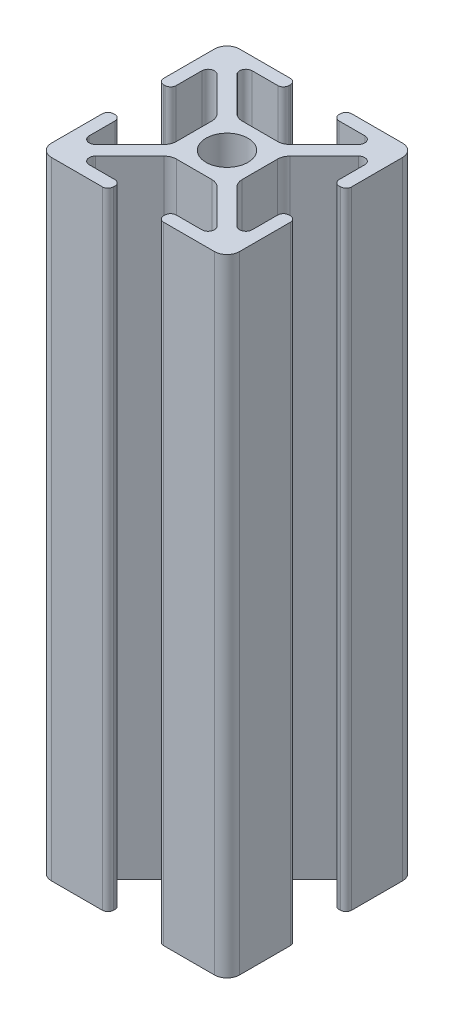
from build123d import *

# Parameters (mm, degrees)
SKETCH1_R       = 3.35
EXTRUSION_DEPTH = 100


with BuildPart() as part:
    # Sketch1 → Extrusion (new body)
    with BuildSketch(Plane(origin=(0, 0, 0), x_dir=(1, 0, 0), z_dir=(0, 1, 0))):
        with BuildLine():
            Line((14.1, -4), (13.9, -4))
            ThreePointArc((13.9, -4), (13.263603897, -4.263603897), (13, -4.9))
            Line((13, -4.9), (13, -8.985786438))
            ThreePointArc((13, -8.985786438), (12.382683432, -9.90966597), (11.292893219, -9.692893219))
            Line((11.292893219, -9.692893219), (5.835786438, -4.235786438))
            ThreePointArc((5.835786438, -4.235786438), (5.402240935, -3.58693974), (5.25, -2.821572875))
            Line((5.25, -2.821572875), (5.25, 2.821572875))
            ThreePointArc((5.25, 2.821572875), (5.402240935, 3.58693974), (5.835786438, 4.235786438))
            Line((5.835786438, 4.235786438), (11.292893219, 9.692893219))
            ThreePointArc((11.292893219, 9.692893219), (12.382683432, 9.90966597), (13, 8.985786438))
            Line((13, 8.985786438), (13, 4.9))
            ThreePointArc((13, 4.9), (13.263603897, 4.263603897), (13.9, 4))
            Line((13.9, 4), (14.1, 4))
            ThreePointArc((14.1, 4), (14.736396103, 4.263603897), (15, 4.9))
            Line((15, 4.9), (15, 13))
            ThreePointArc((15, 13), (14.414213562, 14.414213562), (13, 15))
            Line((13, 15), (4.9, 15))
            ThreePointArc((4.9, 15), (4.263603897, 14.736396103), (4, 14.1))
            Line((4, 14.1), (4, 13.9))
            ThreePointArc((4, 13.9), (4.263603897, 13.263603897), (4.9, 13))
            Line((4.9, 13), (8.985786438, 13))
            ThreePointArc((8.985786438, 13), (9.90966597, 12.382683432), (9.692893219, 11.292893219))
            Line((9.692893219, 11.292893219), (4.235786438, 5.835786438))
            ThreePointArc((4.235786438, 5.835786438), (3.58693974, 5.402240935), (2.821572875, 5.25))
            Line((2.821572875, 5.25), (-2.821572875, 5.25))
            ThreePointArc((-2.821572875, 5.25), (-3.58693974, 5.402240935), (-4.235786438, 5.835786438))
            Line((-4.235786438, 5.835786438), (-9.692893219, 11.292893219))
            ThreePointArc((-9.692893219, 11.292893219), (-9.90966597, 12.382683432), (-8.985786438, 13))
            Line((-8.985786438, 13), (-4.9, 13))
            ThreePointArc((-4.9, 13), (-4.263603897, 13.263603897), (-4, 13.9))
            Line((-4, 13.9), (-4, 14.1))
            ThreePointArc((-4, 14.1), (-4.263603897, 14.736396103), (-4.9, 15))
            Line((-4.9, 15), (-13, 15))
            ThreePointArc((-13, 15), (-14.414213562, 14.414213562), (-15, 13))
            Line((-15, 13), (-15, 4.9))
            ThreePointArc((-15, 4.9), (-14.736396103, 4.263603897), (-14.1, 4))
            Line((-14.1, 4), (-13.9, 4))
            ThreePointArc((-13.9, 4), (-13.263603897, 4.263603897), (-13, 4.9))
            Line((-13, 4.9), (-13, 8.985786438))
            ThreePointArc((-13, 8.985786438), (-12.382683432, 9.90966597), (-11.292893219, 9.692893219))
            Line((-11.292893219, 9.692893219), (-5.835786438, 4.235786438))
            ThreePointArc((-5.835786438, 4.235786438), (-5.402240935, 3.58693974), (-5.25, 2.821572875))
            Line((-5.25, 2.821572875), (-5.25, -2.821572875))
            ThreePointArc((-5.25, -2.821572875), (-5.402240935, -3.58693974), (-5.835786438, -4.235786438))
            Line((-5.835786438, -4.235786438), (-11.292893219, -9.692893219))
            ThreePointArc((-11.292893219, -9.692893219), (-12.382683432, -9.90966597), (-13, -8.985786438))
            Line((-13, -8.985786438), (-13, -4.9))
            ThreePointArc((-13, -4.9), (-13.263603897, -4.263603897), (-13.9, -4))
            Line((-13.9, -4), (-14.1, -4))
            ThreePointArc((-14.1, -4), (-14.736396103, -4.263603897), (-15, -4.9))
            Line((-15, -4.9), (-15, -13))
            ThreePointArc((-15, -13), (-14.414213562, -14.414213562), (-13, -15))
            Line((-13, -15), (-4.9, -15))
            ThreePointArc((-4.9, -15), (-4.263603897, -14.736396103), (-4, -14.1))
            Line((-4, -14.1), (-4, -13.9))
            ThreePointArc((-4, -13.9), (-4.263603897, -13.263603897), (-4.9, -13))
            Line((-4.9, -13), (-8.985786438, -13))
            ThreePointArc((-8.985786438, -13), (-9.90966597, -12.382683432), (-9.692893219, -11.292893219))
            Line((-9.692893219, -11.292893219), (-4.235786438, -5.835786438))
            ThreePointArc((-4.235786438, -5.835786438), (-3.58693974, -5.402240935), (-2.821572875, -5.25))
            Line((-2.821572875, -5.25), (2.821572875, -5.25))
            ThreePointArc((2.821572875, -5.25), (3.58693974, -5.402240935), (4.235786438, -5.835786438))
            Line((4.235786438, -5.835786438), (9.692893219, -11.292893219))
            ThreePointArc((9.692893219, -11.292893219), (9.90966597, -12.382683432), (8.985786438, -13))
            Line((8.985786438, -13), (4.9, -13))
            ThreePointArc((4.9, -13), (4.263603897, -13.263603897), (4, -13.9))
            Line((4, -13.9), (4, -14.1))
            ThreePointArc((4, -14.1), (4.263603897, -14.736396103), (4.9, -15))
            Line((4.9, -15), (13, -15))
            ThreePointArc((13, -15), (14.414213562, -14.414213562), (15, -13))
            Line((15, -13), (15, -4.9))
            ThreePointArc((15, -4.9), (14.736396103, -4.263603897), (14.1, -4))
        make_face()
        Circle(SKETCH1_R, mode=Mode.SUBTRACT)
    extrude(amount=-EXTRUSION_DEPTH)


solid = part.part
